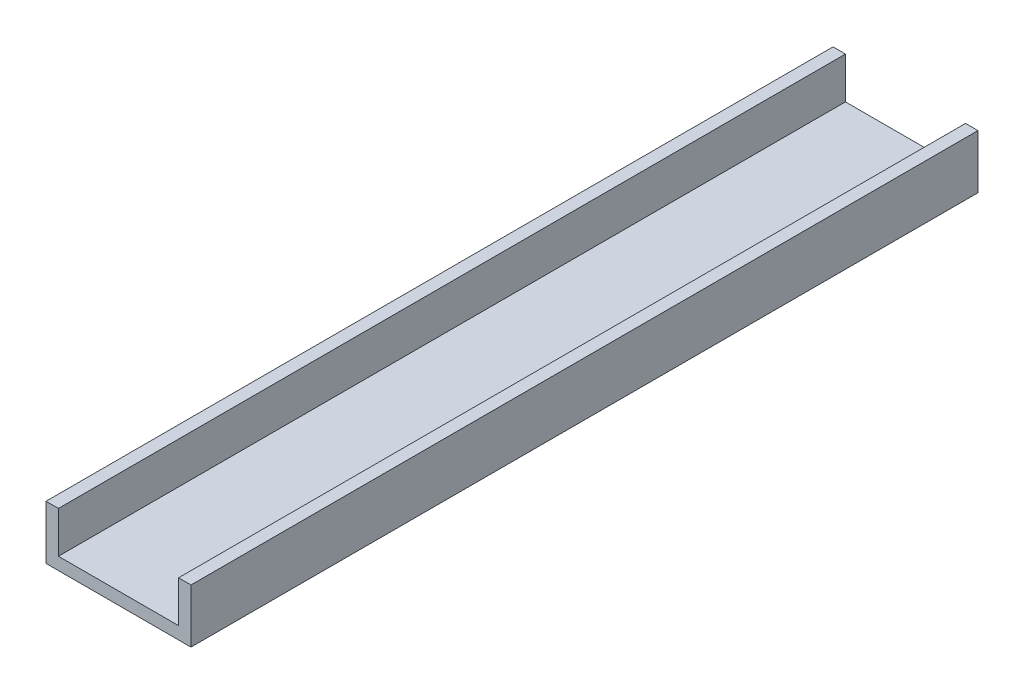
from build123d import *

# Parameters (mm, degrees)
SKETCH1_W           = 35
SKETCH1_H           = 190
BOSS_EXTRUDE1_DEPTH = 3
SKETCH2_W           = 3
SKETCH2_H           = 190
BOSS_EXTRUDE2_DEPTH = 10


with BuildPart() as part:
    # Sketch1 → Boss-Extrude1 (new body)
    with BuildSketch(Plane(origin=(0, 0, 0), x_dir=(1, 0, 0), z_dir=(0, 1, 0))):
        with Locations((17.5, -95)):
            Rectangle(SKETCH1_W, SKETCH1_H)
    extrude(amount=BOSS_EXTRUDE1_DEPTH)

    # Sketch2 → Boss-Extrude2 (add)
    with BuildSketch(Plane(origin=(0, 3, 0), x_dir=(1, 0, 0), z_dir=(0, 1, 0))):
        with Locations((33.5, -95)):
            Rectangle(SKETCH2_W, SKETCH2_H)
        with Locations((1.5, -95)):
            Rectangle(SKETCH2_W, SKETCH2_H)
    extrude(amount=BOSS_EXTRUDE2_DEPTH)


solid = part.part
